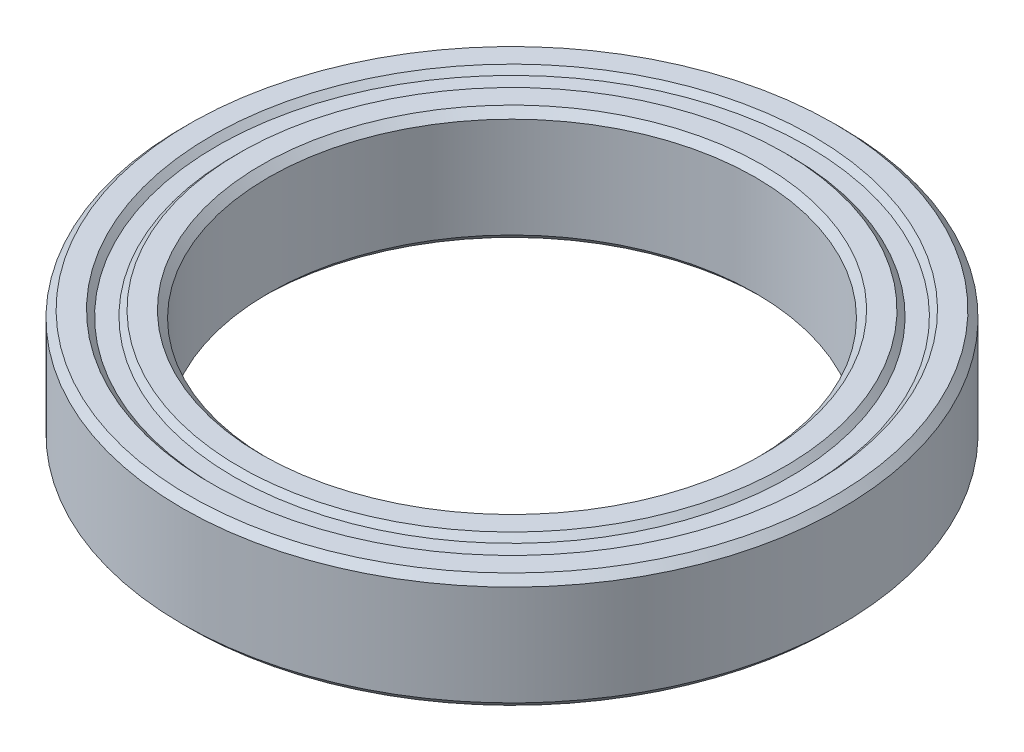
from build123d import *


with BuildPart() as part:
    # Sketch1 → Revolve1 (revolve)
    with BuildSketch(Plane.XY):
        Polygon((8.5, 1.75), (8.5, -1.75), (8.75, -2), (9.5, -2), (9.7, -1.8), (10.3, -1.8), (10.5, -2), (11.25, -2), (11.5, -1.75), (11.5, 1.75), (11.25, 2), (10.5, 2), (10.3, 1.8), (9.7, 1.8), (9.5, 2), (8.75, 2), align=None)
    revolve(axis=Axis((0, -1.349421972, 0), (0, 1, 0)))


solid = part.part
